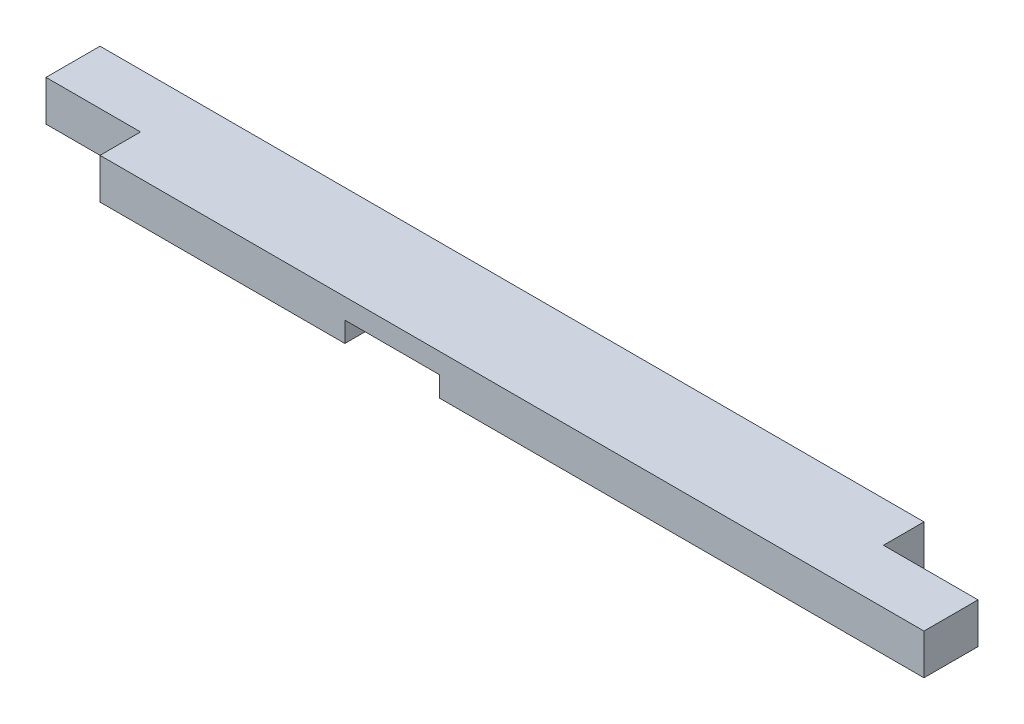
from build123d import *

# Parameters (mm, degrees)
SKETCH1_W           = 863.6
SKETCH1_H           = 88.9
BOSS_EXTRUDE1_DEPTH = 38.1
SKETCH2_W           = 88.9
SKETCH2_H           = 88.9
CUT_EXTRUDE1_DEPTH  = 19.05
SKETCH3_W           = 88.9
SKETCH3_H           = 38.1
CUT_EXTRUDE2_DEPTH  = 39.1
SKETCH4_W           = 88.9
SKETCH4_H           = 38.1
CUT_EXTRUDE3_DEPTH  = 39.1


with BuildPart() as part:
    # Sketch1 → Boss-Extrude1 (new body)
    with BuildSketch(Plane(origin=(0, 0, 0), x_dir=(1, 0, 0), z_dir=(0, 1, 0))):
        with Locations((431.8, 44.45)):
            Rectangle(SKETCH1_W, SKETCH1_H)
    extrude(amount=BOSS_EXTRUDE1_DEPTH)

    # Sketch2 → Cut-Extrude1 (cut)
    with BuildSketch(Plane.XZ):
        with Locations((363.5502, -44.45)):
            Rectangle(SKETCH2_W, SKETCH2_H)
    extrude(amount=-CUT_EXTRUDE1_DEPTH, mode=Mode.SUBTRACT)

    # Sketch3 → Cut-Extrude2 (cut, through all)
    with BuildSketch(Plane(origin=(0, 38.1, 0), x_dir=(1, 0, 0), z_dir=(0, 1, 0))):
        with Locations((44.45, 19.05)):
            Rectangle(SKETCH3_W, SKETCH3_H)
    extrude(amount=-CUT_EXTRUDE2_DEPTH, mode=Mode.SUBTRACT)

    # Sketch4 → Cut-Extrude3 (cut, through all)
    with BuildSketch(Plane(origin=(0, 38.1, 0), x_dir=(1, 0, 0), z_dir=(0, 1, 0))):
        with Locations((819.15, 69.85)):
            Rectangle(SKETCH4_W, SKETCH4_H)
    extrude(amount=-CUT_EXTRUDE3_DEPTH, mode=Mode.SUBTRACT)


solid = part.part
